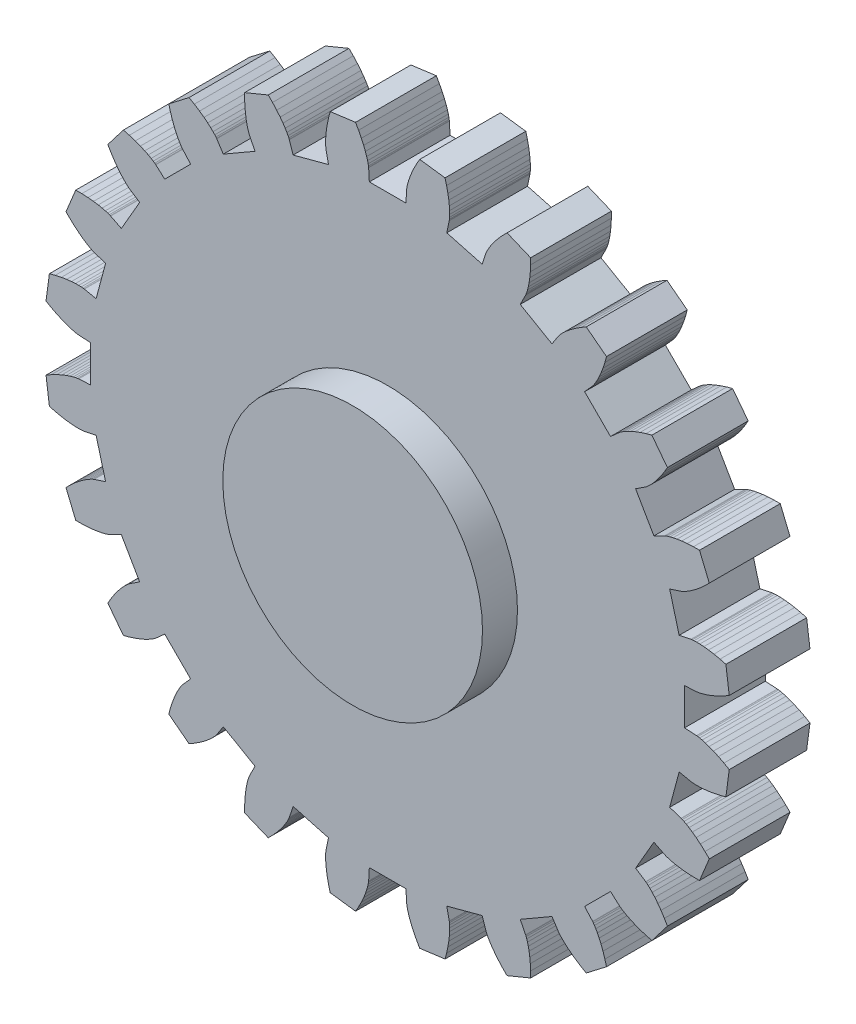
from build123d import *

# Parameters (mm, degrees)
MAIN_GEAR_BODY_DEPTH         = 3
SKETCH2_R                    = 5
CENTRAL_FEATURE_DEPTH        = 1.3
CENTRAL_FEATURE_DEPTH_BACK   = 4.3
SKETCH3_OUTSIDE_W            = 34.792
SKETCH3_OUTSIDE_H            = 34.792
TEETH_CLEARANCE_DEPTH        = 5.3
SKETCH4_R                    = 5
SKETCH4_R_2                  = 4.825
PRINT_CLEARANCE_TOP_DEPTH    = 1.3
SKETCH6_R                    = 5
SKETCH6_R_2                  = 4.825
PRINT_CLEARANCE_BOTTOM_DEPTH = 1.3


with BuildPart() as part:
    # Model → Main Gear Body (new body)
    with BuildSketch(Plane.XY):
        Polygon((11.481280763, -0.655890262), (11.081931867, -0.633076687), (11.081931867, 0.633076687), (11.481280763, 0.655890262), (11.494959484, 0.657119822), (11.535795525, 0.662587053), (11.603342457, 0.674939875), (11.696960474, 0.69678954), (11.81581907, 0.730698092), (11.958900465, 0.779166001), (12.125003794, 0.844620031), (12.312750022, 0.929401369), (12.520587586, 1.035754071), (12.746798737, 1.165813859), (12.614196933, 2.173024562), (12.36203179, 2.240104916), (12.133750014, 2.289041418), (11.930458058, 2.322341602), (11.753073814, 2.342574636), (11.602323381, 2.352358851), (11.478738615, 2.354349128), (11.382655444, 2.351224158), (11.314212973, 2.345673635), (11.273353363, 2.34038543), (11.259822499, 2.338032781), (10.868176499, 2.256709902), (10.540471892, 3.479720146), (10.920308717, 3.605115467), (10.933203113, 3.609843444), (10.971232676, 3.625693529), (11.033280856, 3.655107871), (11.118053808, 3.700443153), (11.224086216, 3.763959167), (11.349747813, 3.847807762), (11.493250558, 3.954022205), (11.652656464, 4.084506989), (11.82588603, 4.24102813), (12.010727273, 4.425203993), (11.621958453, 5.36377495), (11.361023956, 5.363304455), (11.127854994, 5.351489815), (10.922871322, 5.331039494), (10.746294605, 5.304672682), (10.598148527, 5.275106425), (10.478259688, 5.245042794), (10.386259274, 5.21715615), (10.321585504, 5.194080542), (10.28348684, 5.178397283), (10.27102594, 5.172622753), (9.913772864, 4.99270544), (9.280696176, 6.089226427), (9.615135678, 6.30865801), (9.626367017, 6.316562201), (9.658998451, 6.341714983), (9.711319399, 6.386186306), (9.781470148, 6.45191768), (9.867450435, 6.540712645), (9.967128604, 6.654227783), (10.078251291, 6.7939643), (10.198453625, 6.961260207), (10.325269884, 7.157283131), (10.456144594, 7.383023787), (9.837702711, 8.18899294), (9.585781114, 8.121003659), (9.363615046, 8.049243025), (9.170908956, 7.976435853), (9.007173178, 7.905266052), (8.871727365, 7.838364214), (8.76370468, 7.778295462), (8.682056698, 7.727547573), (8.625559041, 7.688519444), (8.592817683, 7.663509918), (8.582275936, 7.654707033), (8.28376199, 7.388456353), (7.388456353, 8.28376199), (7.654707033, 8.582275936), (7.663509918, 8.592817683), (7.688519444, 8.625559041), (7.727547573, 8.682056698), (7.778295462, 8.76370468), (7.838364214, 8.871727365), (7.905266052, 9.007173178), (7.976435853, 9.170908956), (8.049243025, 9.363615046), (8.121003659, 9.585781114), (8.18899294, 9.837702711), (7.383023787, 10.456144594), (7.157283131, 10.325269884), (6.961260207, 10.198453625), (6.7939643, 10.078251291), (6.654227783, 9.967128604), (6.540712645, 9.867450435), (6.45191768, 9.781470148), (6.386186306, 9.711319399), (6.341714983, 9.658998451), (6.316562201, 9.626367017), (6.30865801, 9.615135678), (6.089226427, 9.280696176), (4.99270544, 9.913772864), (5.172622753, 10.27102594), (5.178397283, 10.28348684), (5.194080542, 10.321585504), (5.21715615, 10.386259274), (5.245042794, 10.478259688), (5.275106425, 10.598148527), (5.304672682, 10.746294605), (5.331039494, 10.922871322), (5.351489815, 11.127854994), (5.363304455, 11.361023956), (5.36377495, 11.621958453), (4.425203993, 12.010727273), (4.24102813, 11.82588603), (4.084506989, 11.652656464), (3.954022205, 11.493250558), (3.847807762, 11.349747813), (3.763959167, 11.224086216), (3.700443153, 11.118053808), (3.655107871, 11.033280856), (3.625693529, 10.971232676), (3.609843444, 10.933203113), (3.605115467, 10.920308717), (3.479720146, 10.540471892), (2.256709902, 10.868176499), (2.338032781, 11.259822499), (2.34038543, 11.273353363), (2.345673635, 11.314212973), (2.351224158, 11.382655444), (2.354349128, 11.478738615), (2.352358851, 11.602323381), (2.342574636, 11.753073814), (2.322341602, 11.930458058), (2.289041418, 12.133750014), (2.240104916, 12.36203179), (2.173024562, 12.614196933), (1.165813859, 12.746798737), (1.035754071, 12.520587586), (0.929401369, 12.312750022), (0.844620031, 12.125003794), (0.779166001, 11.958900465), (0.730698092, 11.81581907), (0.69678954, 11.696960474), (0.674939875, 11.603342457), (0.662587053, 11.535795525), (0.657119822, 11.494959484), (0.655890262, 11.481280763), (0.633076687, 11.081931867), (-0.633076687, 11.081931867), (-0.655890262, 11.481280763), (-0.657119822, 11.494959484), (-0.662587053, 11.535795525), (-0.674939875, 11.603342457), (-0.69678954, 11.696960474), (-0.730698092, 11.81581907), (-0.779166001, 11.958900465), (-0.844620031, 12.125003794), (-0.929401369, 12.312750022), (-1.035754071, 12.520587586), (-1.165813859, 12.746798737), (-2.173024562, 12.614196933), (-2.240104916, 12.36203179), (-2.289041418, 12.133750014), (-2.322341602, 11.930458058), (-2.342574636, 11.753073814), (-2.352358851, 11.602323381), (-2.354349128, 11.478738615), (-2.351224158, 11.382655444), (-2.345673635, 11.314212973), (-2.34038543, 11.273353363), (-2.338032781, 11.259822499), (-2.256709902, 10.868176499), (-3.479720146, 10.540471892), (-3.605115467, 10.920308717), (-3.609843444, 10.933203113), (-3.625693529, 10.971232676), (-3.655107871, 11.033280856), (-3.700443153, 11.118053808), (-3.763959167, 11.224086216), (-3.847807762, 11.349747813), (-3.954022205, 11.493250558), (-4.084506989, 11.652656464), (-4.24102813, 11.82588603), (-4.425203993, 12.010727273), (-5.36377495, 11.621958453), (-5.363304455, 11.361023956), (-5.351489815, 11.127854994), (-5.331039494, 10.922871322), (-5.304672682, 10.746294605), (-5.275106425, 10.598148527), (-5.245042794, 10.478259688), (-5.21715615, 10.386259274), (-5.194080542, 10.321585504), (-5.178397283, 10.28348684), (-5.172622753, 10.27102594), (-4.99270544, 9.913772864), (-6.089226427, 9.280696176), (-6.30865801, 9.615135678), (-6.316562201, 9.626367017), (-6.341714983, 9.658998451), (-6.386186306, 9.711319399), (-6.45191768, 9.781470148), (-6.540712645, 9.867450435), (-6.654227783, 9.967128604), (-6.7939643, 10.078251291), (-6.961260207, 10.198453625), (-7.157283131, 10.325269884), (-7.383023787, 10.456144594), (-8.18899294, 9.837702711), (-8.121003659, 9.585781114), (-8.049243025, 9.363615046), (-7.976435853, 9.170908956), (-7.905266052, 9.007173178), (-7.838364214, 8.871727365), (-7.778295462, 8.76370468), (-7.727547573, 8.682056698), (-7.688519444, 8.625559041), (-7.663509918, 8.592817683), (-7.654707033, 8.582275936), (-7.388456353, 8.28376199), (-8.28376199, 7.388456353), (-8.582275936, 7.654707033), (-8.592817683, 7.663509918), (-8.625559041, 7.688519444), (-8.682056698, 7.727547573), (-8.76370468, 7.778295462), (-8.871727365, 7.838364214), (-9.007173178, 7.905266052), (-9.170908956, 7.976435853), (-9.363615046, 8.049243025), (-9.585781114, 8.121003659), (-9.837702711, 8.18899294), (-10.456144594, 7.383023787), (-10.325269884, 7.157283131), (-10.198453625, 6.961260207), (-10.078251291, 6.7939643), (-9.967128604, 6.654227783), (-9.867450435, 6.540712645), (-9.781470148, 6.45191768), (-9.711319399, 6.386186306), (-9.658998451, 6.341714983), (-9.626367017, 6.316562201), (-9.615135678, 6.30865801), (-9.280696176, 6.089226427), (-9.913772864, 4.99270544), (-10.27102594, 5.172622753), (-10.28348684, 5.178397283), (-10.321585504, 5.194080542), (-10.386259274, 5.21715615), (-10.478259688, 5.245042794), (-10.598148527, 5.275106425), (-10.746294605, 5.304672682), (-10.922871322, 5.331039494), (-11.127854994, 5.351489815), (-11.361023956, 5.363304455), (-11.621958453, 5.36377495), (-12.010727273, 4.425203993), (-11.82588603, 4.24102813), (-11.652656464, 4.084506989), (-11.493250558, 3.954022205), (-11.349747813, 3.847807762), (-11.224086216, 3.763959167), (-11.118053808, 3.700443153), (-11.033280856, 3.655107871), (-10.971232676, 3.625693529), (-10.933203113, 3.609843444), (-10.920308717, 3.605115467), (-10.540471892, 3.479720146), (-10.868176499, 2.256709902), (-11.259822499, 2.338032781), (-11.273353363, 2.34038543), (-11.314212973, 2.345673635), (-11.382655444, 2.351224158), (-11.478738615, 2.354349128), (-11.602323381, 2.352358851), (-11.753073814, 2.342574636), (-11.930458058, 2.322341602), (-12.133750014, 2.289041418), (-12.36203179, 2.240104916), (-12.614196933, 2.173024562), (-12.746798737, 1.165813859), (-12.520587586, 1.035754071), (-12.312750022, 0.929401369), (-12.125003794, 0.844620031), (-11.958900465, 0.779166001), (-11.81581907, 0.730698092), (-11.696960474, 0.69678954), (-11.603342457, 0.674939875), (-11.535795525, 0.662587053), (-11.494959484, 0.657119822), (-11.481280763, 0.655890262), (-11.081931867, 0.633076687), (-11.081931867, -0.633076687), (-11.481280763, -0.655890262), (-11.494959484, -0.657119822), (-11.535795525, -0.662587053), (-11.603342457, -0.674939875), (-11.696960474, -0.69678954), (-11.81581907, -0.730698092), (-11.958900465, -0.779166001), (-12.125003794, -0.844620031), (-12.312750022, -0.929401369), (-12.520587586, -1.035754071), (-12.746798737, -1.165813859), (-12.614196933, -2.173024562), (-12.36203179, -2.240104916), (-12.133750014, -2.289041418), (-11.930458058, -2.322341602), (-11.753073814, -2.342574636), (-11.602323381, -2.352358851), (-11.478738615, -2.354349128), (-11.382655444, -2.351224158), (-11.314212973, -2.345673635), (-11.273353363, -2.34038543), (-11.259822499, -2.338032781), (-10.868176499, -2.256709902), (-10.540471892, -3.479720146), (-10.920308717, -3.605115467), (-10.933203113, -3.609843444), (-10.971232676, -3.625693529), (-11.033280856, -3.655107871), (-11.118053808, -3.700443153), (-11.224086216, -3.763959167), (-11.349747813, -3.847807762), (-11.493250558, -3.954022205), (-11.652656464, -4.084506989), (-11.82588603, -4.24102813), (-12.010727273, -4.425203993), (-11.621958453, -5.36377495), (-11.361023956, -5.363304455), (-11.127854994, -5.351489815), (-10.922871322, -5.331039494), (-10.746294605, -5.304672682), (-10.598148527, -5.275106425), (-10.478259688, -5.245042794), (-10.386259274, -5.21715615), (-10.321585504, -5.194080542), (-10.28348684, -5.178397283), (-10.27102594, -5.172622753), (-9.913772864, -4.99270544), (-9.280696176, -6.089226427), (-9.615135678, -6.30865801), (-9.626367017, -6.316562201), (-9.658998451, -6.341714983), (-9.711319399, -6.386186306), (-9.781470148, -6.45191768), (-9.867450435, -6.540712645), (-9.967128604, -6.654227783), (-10.078251291, -6.7939643), (-10.198453625, -6.961260207), (-10.325269884, -7.157283131), (-10.456144594, -7.383023787), (-9.837702711, -8.18899294), (-9.585781114, -8.121003659), (-9.363615046, -8.049243025), (-9.170908956, -7.976435853), (-9.007173178, -7.905266052), (-8.871727365, -7.838364214), (-8.76370468, -7.778295462), (-8.682056698, -7.727547573), (-8.625559041, -7.688519444), (-8.592817683, -7.663509918), (-8.582275936, -7.654707033), (-8.28376199, -7.388456353), (-7.388456353, -8.28376199), (-7.654707033, -8.582275936), (-7.663509918, -8.592817683), (-7.688519444, -8.625559041), (-7.727547573, -8.682056698), (-7.778295462, -8.76370468), (-7.838364214, -8.871727365), (-7.905266052, -9.007173178), (-7.976435853, -9.170908956), (-8.049243025, -9.363615046), (-8.121003659, -9.585781114), (-8.18899294, -9.837702711), (-7.383023787, -10.456144594), (-7.157283131, -10.325269884), (-6.961260207, -10.198453625), (-6.7939643, -10.078251291), (-6.654227783, -9.967128604), (-6.540712645, -9.867450435), (-6.45191768, -9.781470148), (-6.386186306, -9.711319399), (-6.341714983, -9.658998451), (-6.316562201, -9.626367017), (-6.30865801, -9.615135678), (-6.089226427, -9.280696176), (-4.99270544, -9.913772864), (-5.172622753, -10.27102594), (-5.178397283, -10.28348684), (-5.194080542, -10.321585504), (-5.21715615, -10.386259274), (-5.245042794, -10.478259688), (-5.275106425, -10.598148527), (-5.304672682, -10.746294605), (-5.331039494, -10.922871322), (-5.351489815, -11.127854994), (-5.363304455, -11.361023956), (-5.36377495, -11.621958453), (-4.425203993, -12.010727273), (-4.24102813, -11.82588603), (-4.084506989, -11.652656464), (-3.954022205, -11.493250558), (-3.847807762, -11.349747813), (-3.763959167, -11.224086216), (-3.700443153, -11.118053808), (-3.655107871, -11.033280856), (-3.625693529, -10.971232676), (-3.609843444, -10.933203113), (-3.605115467, -10.920308717), (-3.479720146, -10.540471892), (-2.256709902, -10.868176499), (-2.338032781, -11.259822499), (-2.34038543, -11.273353363), (-2.345673635, -11.314212973), (-2.351224158, -11.382655444), (-2.354349128, -11.478738615), (-2.352358851, -11.602323381), (-2.342574636, -11.753073814), (-2.322341602, -11.930458058), (-2.289041418, -12.133750014), (-2.240104916, -12.36203179), (-2.173024562, -12.614196933), (-1.165813859, -12.746798737), (-1.035754071, -12.520587586), (-0.929401369, -12.312750022), (-0.844620031, -12.125003794), (-0.779166001, -11.958900465), (-0.730698092, -11.81581907), (-0.69678954, -11.696960474), (-0.674939875, -11.603342457), (-0.662587053, -11.535795525), (-0.657119822, -11.494959484), (-0.655890262, -11.481280763), (-0.633076687, -11.081931867), (0.633076687, -11.081931867), (0.655890262, -11.481280763), (0.657119822, -11.494959484), (0.662587053, -11.535795525), (0.674939875, -11.603342457), (0.69678954, -11.696960474), (0.730698092, -11.81581907), (0.779166001, -11.958900465), (0.844620031, -12.125003794), (0.929401369, -12.312750022), (1.035754071, -12.520587586), (1.165813859, -12.746798737), (2.173024562, -12.614196933), (2.240104916, -12.36203179), (2.289041418, -12.133750014), (2.322341602, -11.930458058), (2.342574636, -11.753073814), (2.352358851, -11.602323381), (2.354349128, -11.478738615), (2.351224158, -11.382655444), (2.345673635, -11.314212973), (2.34038543, -11.273353363), (2.338032781, -11.259822499), (2.256709902, -10.868176499), (3.479720146, -10.540471892), (3.605115467, -10.920308717), (3.609843444, -10.933203113), (3.625693529, -10.971232676), (3.655107871, -11.033280856), (3.700443153, -11.118053808), (3.763959167, -11.224086216), (3.847807762, -11.349747813), (3.954022205, -11.493250558), (4.084506989, -11.652656464), (4.24102813, -11.82588603), (4.425203993, -12.010727273), (5.36377495, -11.621958453), (5.363304455, -11.361023956), (5.351489815, -11.127854994), (5.331039494, -10.922871322), (5.304672682, -10.746294605), (5.275106425, -10.598148527), (5.245042794, -10.478259688), (5.21715615, -10.386259274), (5.194080542, -10.321585504), (5.178397283, -10.28348684), (5.172622753, -10.27102594), (4.99270544, -9.913772864), (6.089226427, -9.280696176), (6.30865801, -9.615135678), (6.316562201, -9.626367017), (6.341714983, -9.658998451), (6.386186306, -9.711319399), (6.45191768, -9.781470148), (6.540712645, -9.867450435), (6.654227783, -9.967128604), (6.7939643, -10.078251291), (6.961260207, -10.198453625), (7.157283131, -10.325269884), (7.383023787, -10.456144594), (8.18899294, -9.837702711), (8.121003659, -9.585781114), (8.049243025, -9.363615046), (7.976435853, -9.170908956), (7.905266052, -9.007173178), (7.838364214, -8.871727365), (7.778295462, -8.76370468), (7.727547573, -8.682056698), (7.688519444, -8.625559041), (7.663509918, -8.592817683), (7.654707033, -8.582275936), (7.388456353, -8.28376199), (8.28376199, -7.388456353), (8.582275936, -7.654707033), (8.592817683, -7.663509918), (8.625559041, -7.688519444), (8.682056698, -7.727547573), (8.76370468, -7.778295462), (8.871727365, -7.838364214), (9.007173178, -7.905266052), (9.170908956, -7.976435853), (9.363615046, -8.049243025), (9.585781114, -8.121003659), (9.837702711, -8.18899294), (10.456144594, -7.383023787), (10.325269884, -7.157283131), (10.198453625, -6.961260207), (10.078251291, -6.7939643), (9.967128604, -6.654227783), (9.867450435, -6.540712645), (9.781470148, -6.45191768), (9.711319399, -6.386186306), (9.658998451, -6.341714983), (9.626367017, -6.316562201), (9.615135678, -6.30865801), (9.280696176, -6.089226427), (9.913772864, -4.99270544), (10.27102594, -5.172622753), (10.28348684, -5.178397283), (10.321585504, -5.194080542), (10.386259274, -5.21715615), (10.478259688, -5.245042794), (10.598148527, -5.275106425), (10.746294605, -5.304672682), (10.922871322, -5.331039494), (11.127854994, -5.351489815), (11.361023956, -5.363304455), (11.621958453, -5.36377495), (12.010727273, -4.425203993), (11.82588603, -4.24102813), (11.652656464, -4.084506989), (11.493250558, -3.954022205), (11.349747813, -3.847807762), (11.224086216, -3.763959167), (11.118053808, -3.700443153), (11.033280856, -3.655107871), (10.971232676, -3.625693529), (10.933203113, -3.609843444), (10.920308717, -3.605115467), (10.540471892, -3.479720146), (10.868176499, -2.256709902), (11.259822499, -2.338032781), (11.273353363, -2.34038543), (11.314212973, -2.345673635), (11.382655444, -2.351224158), (11.478738615, -2.354349128), (11.602323381, -2.352358851), (11.753073814, -2.342574636), (11.930458058, -2.322341602), (12.133750014, -2.289041418), (12.36203179, -2.240104916), (12.614196933, -2.173024562), (12.746798737, -1.165813859), (12.520587586, -1.035754071), (12.312750022, -0.929401369), (12.125003794, -0.844620031), (11.958900465, -0.779166001), (11.81581907, -0.730698092), (11.696960474, -0.69678954), (11.603342457, -0.674939875), (11.535795525, -0.662587053), (11.494959484, -0.657119822), align=None)
    extrude(amount=MAIN_GEAR_BODY_DEPTH)

    # Sketch2 → Central Feature (add, two sides)
    with BuildSketch(Plane.XY.offset(3)) as central_feature_sk:
        Circle(SKETCH2_R)
    extrude(amount=CENTRAL_FEATURE_DEPTH)
    extrude(central_feature_sk.sketch, amount=-CENTRAL_FEATURE_DEPTH_BACK)

    # Sketch3 outside → Teeth Clearance (cut, through all)
    with BuildSketch(Plane(origin=(0, 0, 0), x_dir=(-1, 0, 0), z_dir=(0, 0, -1))):
        Rectangle(SKETCH3_OUTSIDE_W, SKETCH3_OUTSIDE_H)
        Polygon((-11.477615752, -0.705762411), (-11.489401209, -0.706821789), (-11.527976246, -0.711986312), (-11.59315705, -0.723906422), (-11.684412493, -0.745204681), (-11.800930862, -0.778445602), (-11.941703887, -0.826131565), (-12.105537815, -0.890691324), (-12.291059816, -0.974468259), (-12.496724072, -1.079708856), (-12.692857237, -1.192475348), (-12.568993946, -2.133310454), (-12.35035774, -2.191471522), (-12.124463053, -2.239896306), (-11.923579494, -2.272801984), (-11.748618777, -2.292758582), (-11.600300442, -2.302384946), (-11.479148956, -2.304336036), (-11.385490572, -2.301289929), (-11.319445598, -2.295933837), (-11.280848297, -2.290938429), (-11.269190232, -2.288911409), (-10.832102983, -2.198152934), (-10.479952826, -3.512395209), (-10.903860726, -3.652339689), (-10.914970416, -3.656413271), (-10.950894363, -3.67138577), (-11.010769034, -3.699769746), (-11.093402628, -3.743960931), (-11.197347347, -3.806226368), (-11.320981611, -3.888722212), (-11.462523738, -3.993485491), (-11.620041165, -4.122424424), (-11.79145931, -4.27730886), (-11.951723284, -4.436995926), (-11.588574488, -5.313714674), (-11.362334938, -5.313306738), (-11.13160417, -5.30161564), (-10.929048936, -5.281407594), (-10.754884713, -5.255401021), (-10.609128716, -5.226311764), (-10.491600388, -5.196840061), (-10.401921726, -5.169657174), (-10.339513439, -5.14738989), (-10.303524216, -5.132574979), (-10.292788022, -5.127599699), (-9.894084181, -4.926807239), (-9.213782319, -6.105124628), (-9.58702561, -6.350016053), (-9.596702427, -6.35682623), (-9.627527127, -6.380586356), (-9.678015304, -6.423499876), (-9.746395706, -6.487572431), (-9.830683114, -6.574619098), (-9.928753148, -6.686302866), (-10.038357612, -6.824130221), (-10.157135911, -6.989444176), (-10.282626082, -7.183417334), (-10.39609914, -7.379142564), (-9.81841283, -8.13199802), (-9.599987788, -8.07304888), (-9.380144858, -8.00203863), (-9.189721754, -7.930094003), (-9.028223029, -7.859896565), (-8.894962401, -7.794074073), (-8.789066591, -7.735188024), (-8.709479105, -7.685720826), (-8.654960526, -7.648059828), (-8.624031987, -7.624435026), (-8.614949317, -7.616850543), (-8.281799893, -7.319707773), (-7.319707773, -8.281799893), (-7.616850543, -8.614949317), (-7.624435026, -8.624031987), (-7.648059828, -8.654960526), (-7.685720826, -8.709479105), (-7.735188024, -8.789066591), (-7.794074073, -8.894962401), (-7.859896565, -9.028223029), (-7.930094003, -9.189721754), (-8.00203863, -9.380144858), (-8.07304888, -9.599987788), (-8.13199802, -9.81841283), (-7.379142564, -10.39609914), (-7.183417334, -10.282626082), (-6.989444176, -10.157135911), (-6.824130221, -10.038357612), (-6.686302866, -9.928753148), (-6.574619098, -9.830683114), (-6.487572431, -9.746395706), (-6.423499876, -9.678015304), (-6.380586356, -9.627527127), (-6.35682623, -9.596702427), (-6.350016053, -9.58702561), (-6.105124628, -9.213782319), (-4.926807239, -9.894084181), (-5.127599699, -10.292788022), (-5.132574979, -10.303524216), (-5.14738989, -10.339513439), (-5.169657174, -10.401921726), (-5.196840061, -10.491600388), (-5.226311764, -10.609128716), (-5.255401021, -10.754884713), (-5.281407594, -10.929048936), (-5.30161564, -11.13160417), (-5.313306738, -11.362334938), (-5.313714674, -11.588574488), (-4.436995926, -11.951723284), (-4.27730886, -11.79145931), (-4.122424424, -11.620041165), (-3.993485491, -11.462523738), (-3.888722212, -11.320981611), (-3.806226368, -11.197347347), (-3.743960931, -11.093402628), (-3.699769746, -11.010769034), (-3.67138577, -10.950894363), (-3.656413271, -10.914970416), (-3.652339689, -10.903860726), (-3.512395209, -10.479952826), (-2.198152934, -10.832102983), (-2.288911409, -11.269190232), (-2.290938429, -11.280848297), (-2.295933837, -11.319445598), (-2.301289929, -11.385490572), (-2.304336036, -11.479148956), (-2.302384946, -11.600300442), (-2.292758582, -11.748618777), (-2.272801984, -11.923579494), (-2.239896306, -12.124463053), (-2.191471522, -12.35035774), (-2.133310454, -12.568993946), (-1.192475348, -12.692857237), (-1.079708856, -12.496724072), (-0.974468259, -12.291059816), (-0.890691324, -12.105537815), (-0.826131565, -11.941703887), (-0.778445602, -11.800930862), (-0.745204681, -11.684412493), (-0.723906422, -11.59315705), (-0.711986312, -11.527976246), (-0.706821789, -11.489401209), (-0.705762411, -11.477615752), (-0.680301862, -11.031931867), (0.680301862, -11.031931867), (0.705762411, -11.477615752), (0.706821789, -11.489401209), (0.711986312, -11.527976246), (0.723906422, -11.59315705), (0.745204681, -11.684412493), (0.778445602, -11.800930862), (0.826131565, -11.941703887), (0.890691324, -12.105537815), (0.974468259, -12.291059816), (1.079708856, -12.496724072), (1.192475348, -12.692857237), (2.133310454, -12.568993946), (2.191471522, -12.35035774), (2.239896306, -12.124463053), (2.272801984, -11.923579494), (2.292758582, -11.748618777), (2.302384946, -11.600300442), (2.304336036, -11.479148956), (2.301289929, -11.385490572), (2.295933837, -11.319445598), (2.290938429, -11.280848297), (2.288911409, -11.269190232), (2.198152934, -10.832102983), (3.512395209, -10.479952826), (3.652339689, -10.903860726), (3.656413271, -10.914970416), (3.67138577, -10.950894363), (3.699769746, -11.010769034), (3.743960931, -11.093402628), (3.806226368, -11.197347347), (3.888722212, -11.320981611), (3.993485491, -11.462523738), (4.122424424, -11.620041165), (4.27730886, -11.79145931), (4.436995926, -11.951723284), (5.313714674, -11.588574488), (5.313306738, -11.362334938), (5.30161564, -11.13160417), (5.281407594, -10.929048936), (5.255401021, -10.754884713), (5.226311764, -10.609128716), (5.196840061, -10.491600388), (5.169657174, -10.401921726), (5.14738989, -10.339513439), (5.132574979, -10.303524216), (5.127599699, -10.292788022), (4.926807239, -9.894084181), (6.105124628, -9.213782319), (6.350016053, -9.58702561), (6.35682623, -9.596702427), (6.380586356, -9.627527127), (6.423499876, -9.678015304), (6.487572431, -9.746395706), (6.574619098, -9.830683114), (6.686302866, -9.928753148), (6.824130221, -10.038357612), (6.989444176, -10.157135911), (7.183417334, -10.282626082), (7.379142564, -10.39609914), (8.13199802, -9.81841283), (8.07304888, -9.599987788), (8.00203863, -9.380144858), (7.930094003, -9.189721754), (7.859896565, -9.028223029), (7.794074073, -8.894962401), (7.735188024, -8.789066591), (7.685720826, -8.709479105), (7.648059828, -8.654960526), (7.624435026, -8.624031987), (7.616850543, -8.614949317), (7.319707773, -8.281799893), (8.281799893, -7.319707773), (8.614949317, -7.616850543), (8.624031987, -7.624435026), (8.654960526, -7.648059828), (8.709479105, -7.685720826), (8.789066591, -7.735188024), (8.894962401, -7.794074073), (9.028223029, -7.859896565), (9.189721754, -7.930094003), (9.380144858, -8.00203863), (9.599987788, -8.07304888), (9.81841283, -8.13199802), (10.39609914, -7.379142564), (10.282626082, -7.183417334), (10.157135911, -6.989444176), (10.038357612, -6.824130221), (9.928753148, -6.686302866), (9.830683114, -6.574619098), (9.746395706, -6.487572431), (9.678015304, -6.423499876), (9.627527127, -6.380586356), (9.596702427, -6.35682623), (9.58702561, -6.350016053), (9.213782319, -6.105124628), (9.894084181, -4.926807239), (10.292788022, -5.127599699), (10.303524216, -5.132574979), (10.339513439, -5.14738989), (10.401921726, -5.169657174), (10.491600388, -5.196840061), (10.609128716, -5.226311764), (10.754884713, -5.255401021), (10.929048936, -5.281407594), (11.13160417, -5.30161564), (11.362334938, -5.313306738), (11.588574488, -5.313714674), (11.951723284, -4.436995926), (11.79145931, -4.27730886), (11.620041165, -4.122424424), (11.462523738, -3.993485491), (11.320981611, -3.888722212), (11.197347347, -3.806226368), (11.093402628, -3.743960931), (11.010769034, -3.699769746), (10.950894363, -3.67138577), (10.914970416, -3.656413271), (10.903860726, -3.652339689), (10.479952826, -3.512395209), (10.832102983, -2.198152934), (11.269190232, -2.288911409), (11.280848297, -2.290938429), (11.319445598, -2.295933837), (11.385490572, -2.301289929), (11.479148956, -2.304336036), (11.600300442, -2.302384946), (11.748618777, -2.292758582), (11.923579494, -2.272801984), (12.124463053, -2.239896306), (12.35035774, -2.191471522), (12.568993946, -2.133310454), (12.692857237, -1.192475348), (12.496724072, -1.079708856), (12.291059816, -0.974468259), (12.105537815, -0.890691324), (11.941703887, -0.826131565), (11.800930862, -0.778445602), (11.684412493, -0.745204681), (11.59315705, -0.723906422), (11.527976246, -0.711986312), (11.489401209, -0.706821789), (11.477615752, -0.705762411), (11.031931867, -0.680301862), (11.031931867, 0.680301862), (11.477615752, 0.705762411), (11.489401209, 0.706821789), (11.527976246, 0.711986312), (11.59315705, 0.723906422), (11.684412493, 0.745204681), (11.800930862, 0.778445602), (11.941703887, 0.826131565), (12.105537815, 0.890691324), (12.291059816, 0.974468259), (12.496724072, 1.079708856), (12.692857237, 1.192475348), (12.568993946, 2.133310454), (12.35035774, 2.191471522), (12.124463053, 2.239896306), (11.923579494, 2.272801984), (11.748618777, 2.292758582), (11.600300442, 2.302384946), (11.479148956, 2.304336036), (11.385490572, 2.301289929), (11.319445598, 2.295933837), (11.280848297, 2.290938429), (11.269190232, 2.288911409), (10.832102983, 2.198152934), (10.479952826, 3.512395209), (10.903860726, 3.652339689), (10.914970416, 3.656413271), (10.950894363, 3.67138577), (11.010769034, 3.699769746), (11.093402628, 3.743960931), (11.197347347, 3.806226368), (11.320981611, 3.888722212), (11.462523738, 3.993485491), (11.620041165, 4.122424424), (11.79145931, 4.27730886), (11.951723284, 4.436995926), (11.588574488, 5.313714674), (11.362334938, 5.313306738), (11.13160417, 5.30161564), (10.929048936, 5.281407594), (10.754884713, 5.255401021), (10.609128716, 5.226311764), (10.491600388, 5.196840061), (10.401921726, 5.169657174), (10.339513439, 5.14738989), (10.303524216, 5.132574979), (10.292788022, 5.127599699), (9.894084181, 4.926807239), (9.213782319, 6.105124628), (9.58702561, 6.350016053), (9.596702427, 6.35682623), (9.627527127, 6.380586356), (9.678015304, 6.423499876), (9.746395706, 6.487572431), (9.830683114, 6.574619098), (9.928753148, 6.686302866), (10.038357612, 6.824130221), (10.157135911, 6.989444176), (10.282626082, 7.183417334), (10.39609914, 7.379142564), (9.81841283, 8.13199802), (9.599987788, 8.07304888), (9.380144858, 8.00203863), (9.189721754, 7.930094003), (9.028223029, 7.859896565), (8.894962401, 7.794074073), (8.789066591, 7.735188024), (8.709479105, 7.685720826), (8.654960526, 7.648059828), (8.624031987, 7.624435026), (8.614949317, 7.616850543), (8.281799893, 7.319707773), (7.319707773, 8.281799893), (7.616850543, 8.614949317), (7.624435026, 8.624031987), (7.648059828, 8.654960526), (7.685720826, 8.709479105), (7.735188024, 8.789066591), (7.794074073, 8.894962401), (7.859896565, 9.028223029), (7.930094003, 9.189721754), (8.00203863, 9.380144858), (8.07304888, 9.599987788), (8.13199802, 9.81841283), (7.379142564, 10.39609914), (7.183417334, 10.282626082), (6.989444176, 10.157135911), (6.824130221, 10.038357612), (6.686302866, 9.928753148), (6.574619098, 9.830683114), (6.487572431, 9.746395706), (6.423499876, 9.678015304), (6.380586356, 9.627527127), (6.35682623, 9.596702427), (6.350016053, 9.58702561), (6.105124628, 9.213782319), (4.926807239, 9.894084181), (5.127599699, 10.292788022), (5.132574979, 10.303524216), (5.14738989, 10.339513439), (5.169657174, 10.401921726), (5.196840061, 10.491600388), (5.226311764, 10.609128716), (5.255401021, 10.754884713), (5.281407594, 10.929048936), (5.30161564, 11.13160417), (5.313306738, 11.362334938), (5.313714674, 11.588574488), (4.436995926, 11.951723284), (4.27730886, 11.79145931), (4.122424424, 11.620041165), (3.993485491, 11.462523738), (3.888722212, 11.320981611), (3.806226368, 11.197347347), (3.743960931, 11.093402628), (3.699769746, 11.010769034), (3.67138577, 10.950894363), (3.656413271, 10.914970416), (3.652339689, 10.903860726), (3.512395209, 10.479952826), (2.198152934, 10.832102983), (2.288911409, 11.269190232), (2.290938429, 11.280848297), (2.295933837, 11.319445598), (2.301289929, 11.385490572), (2.304336036, 11.479148956), (2.302384946, 11.600300442), (2.292758582, 11.748618777), (2.272801984, 11.923579494), (2.239896306, 12.124463053), (2.191471522, 12.35035774), (2.133310454, 12.568993946), (1.192475348, 12.692857237), (1.079708856, 12.496724072), (0.974468259, 12.291059816), (0.890691324, 12.105537815), (0.826131565, 11.941703887), (0.778445602, 11.800930862), (0.745204681, 11.684412493), (0.723906422, 11.59315705), (0.711986312, 11.527976246), (0.706821789, 11.489401209), (0.705762411, 11.477615752), (0.680301862, 11.031931867), (-0.680301862, 11.031931867), (-0.705762411, 11.477615752), (-0.706821789, 11.489401209), (-0.711986312, 11.527976246), (-0.723906422, 11.59315705), (-0.745204681, 11.684412493), (-0.778445602, 11.800930862), (-0.826131565, 11.941703887), (-0.890691324, 12.105537815), (-0.974468259, 12.291059816), (-1.079708856, 12.496724072), (-1.192475348, 12.692857237), (-2.133310454, 12.568993946), (-2.191471522, 12.35035774), (-2.239896306, 12.124463053), (-2.272801984, 11.923579494), (-2.292758582, 11.748618777), (-2.302384946, 11.600300442), (-2.304336036, 11.479148956), (-2.301289929, 11.385490572), (-2.295933837, 11.319445598), (-2.290938429, 11.280848297), (-2.288911409, 11.269190232), (-2.198152934, 10.832102983), (-3.512395209, 10.479952826), (-3.652339689, 10.903860726), (-3.656413271, 10.914970416), (-3.67138577, 10.950894363), (-3.699769746, 11.010769034), (-3.743960931, 11.093402628), (-3.806226368, 11.197347347), (-3.888722212, 11.320981611), (-3.993485491, 11.462523738), (-4.122424424, 11.620041165), (-4.27730886, 11.79145931), (-4.436995926, 11.951723284), (-5.313714674, 11.588574488), (-5.313306738, 11.362334938), (-5.30161564, 11.13160417), (-5.281407594, 10.929048936), (-5.255401021, 10.754884713), (-5.226311764, 10.609128716), (-5.196840061, 10.491600388), (-5.169657174, 10.401921726), (-5.14738989, 10.339513439), (-5.132574979, 10.303524216), (-5.127599699, 10.292788022), (-4.926807239, 9.894084181), (-6.105124628, 9.213782319), (-6.350016053, 9.58702561), (-6.35682623, 9.596702427), (-6.380586356, 9.627527127), (-6.423499876, 9.678015304), (-6.487572431, 9.746395706), (-6.574619098, 9.830683114), (-6.686302866, 9.928753148), (-6.824130221, 10.038357612), (-6.989444176, 10.157135911), (-7.183417334, 10.282626082), (-7.379142564, 10.39609914), (-8.13199802, 9.81841283), (-8.07304888, 9.599987788), (-8.00203863, 9.380144858), (-7.930094003, 9.189721754), (-7.859896565, 9.028223029), (-7.794074073, 8.894962401), (-7.735188024, 8.789066591), (-7.685720826, 8.709479105), (-7.648059828, 8.654960526), (-7.624435026, 8.624031987), (-7.616850543, 8.614949317), (-7.319707773, 8.281799893), (-8.281799893, 7.319707773), (-8.614949317, 7.616850543), (-8.624031987, 7.624435026), (-8.654960526, 7.648059828), (-8.709479105, 7.685720826), (-8.789066591, 7.735188024), (-8.894962401, 7.794074073), (-9.028223029, 7.859896565), (-9.189721754, 7.930094003), (-9.380144858, 8.00203863), (-9.599987788, 8.07304888), (-9.81841283, 8.13199802), (-10.39609914, 7.379142564), (-10.282626082, 7.183417334), (-10.157135911, 6.989444176), (-10.038357612, 6.824130221), (-9.928753148, 6.686302866), (-9.830683114, 6.574619098), (-9.746395706, 6.487572431), (-9.678015304, 6.423499876), (-9.627527127, 6.380586356), (-9.596702427, 6.35682623), (-9.58702561, 6.350016053), (-9.213782319, 6.105124628), (-9.894084181, 4.926807239), (-10.292788022, 5.127599699), (-10.303524216, 5.132574979), (-10.339513439, 5.14738989), (-10.401921726, 5.169657174), (-10.491600388, 5.196840061), (-10.609128716, 5.226311764), (-10.754884713, 5.255401021), (-10.929048936, 5.281407594), (-11.13160417, 5.30161564), (-11.362334938, 5.313306738), (-11.588574488, 5.313714674), (-11.951723284, 4.436995926), (-11.79145931, 4.27730886), (-11.620041165, 4.122424424), (-11.462523738, 3.993485491), (-11.320981611, 3.888722212), (-11.197347347, 3.806226368), (-11.093402628, 3.743960931), (-11.010769034, 3.699769746), (-10.950894363, 3.67138577), (-10.914970416, 3.656413271), (-10.903860726, 3.652339689), (-10.479952826, 3.512395209), (-10.832102983, 2.198152934), (-11.269190232, 2.288911409), (-11.280848297, 2.290938429), (-11.319445598, 2.295933837), (-11.385490572, 2.301289929), (-11.479148956, 2.304336036), (-11.600300442, 2.302384946), (-11.748618777, 2.292758582), (-11.923579494, 2.272801984), (-12.124463053, 2.239896306), (-12.35035774, 2.191471522), (-12.568993946, 2.133310454), (-12.692857237, 1.192475348), (-12.496724072, 1.079708856), (-12.291059816, 0.974468259), (-12.105537815, 0.890691324), (-11.941703887, 0.826131565), (-11.800930862, 0.778445602), (-11.684412493, 0.745204681), (-11.59315705, 0.723906422), (-11.527976246, 0.711986312), (-11.489401209, 0.706821789), (-11.477615752, 0.705762411), (-11.031931867, 0.680301862), (-11.031931867, -0.680301862), align=None, mode=Mode.SUBTRACT)
    extrude(amount=-TEETH_CLEARANCE_DEPTH, mode=Mode.SUBTRACT)

    # Sketch4 → Print Clearance - Top (cut)
    with BuildSketch(Plane(origin=(0, 0, -1.3), x_dir=(-1, 0, 0), z_dir=(0, 0, -1))):
        Circle(SKETCH4_R)
        Circle(SKETCH4_R_2, mode=Mode.SUBTRACT)
    extrude(amount=-PRINT_CLEARANCE_TOP_DEPTH, mode=Mode.SUBTRACT)

    # Sketch6 → Print Clearance - Bottom (cut)
    with BuildSketch(Plane.XY.offset(4.3)):
        Circle(SKETCH6_R)
        Circle(SKETCH6_R_2, mode=Mode.SUBTRACT)
    extrude(amount=-PRINT_CLEARANCE_BOTTOM_DEPTH, mode=Mode.SUBTRACT)


solid = part.part
